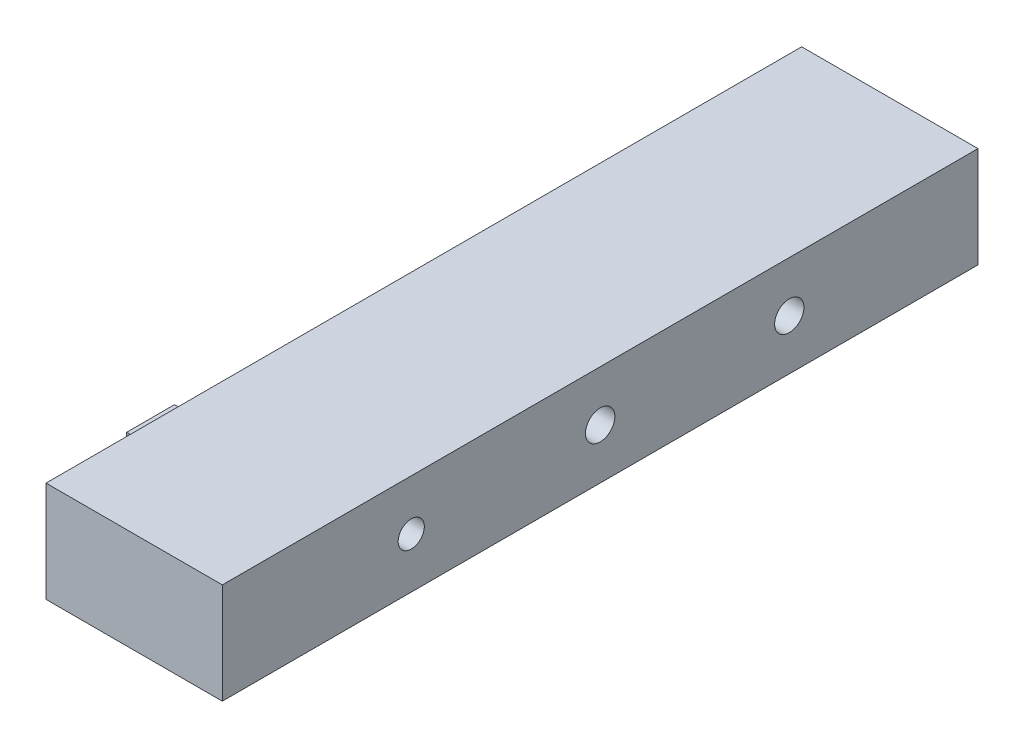
from build123d import *

# Parameters (mm, degrees)
SKETCH1_W                = 30
SKETCH1_H                = 4
BOSS_EXTRUDE1_DEPTH      = 7
SKETCH2_W                = 1.9
SKETCH2_H                = 1.9
BOSS_EXTRUDE2_DEPTH      = 1
SKETCH3_W                = 1.9
SKETCH3_H                = 1.769397694
BOSS_EXTRUDE3_DEPTH      = 1
BOSS_EXTRUDE3_DEPTH_BACK = 1
SKETCH4_R                = 0.519223145
SKETCH4_R_2              = 0.583770961
SKETCH4_R_3              = 0.581603631
CUT_EXTRUDE2_DEPTH       = 1
CUT_EXTRUDE2_DEPTH_BACK  = 3


with BuildPart() as part:
    # Sketch1 → Boss-Extrude1 (new body)
    with BuildSketch(Plane(origin=(0, 0, 0), x_dir=(0, 0, -1), z_dir=(1, 0, 0))):
        with Locations((15, 2)):
            Rectangle(SKETCH1_W, SKETCH1_H)
    extrude(amount=BOSS_EXTRUDE1_DEPTH)

    # Sketch2 → Boss-Extrude2 (add)
    with BuildSketch(Plane(origin=(0, 0, 0), x_dir=(0, 0, -1), z_dir=(1, 0, 0))):
        with Locations((5.150612861, 2.196174594)):
            Rectangle(SKETCH2_W, SKETCH2_H)
    extrude(amount=-BOSS_EXTRUDE2_DEPTH)

    # Sketch3 → Boss-Extrude3 (add, two sides)
    with BuildSketch(Plane(origin=(0, 0, 0), x_dir=(0, 0, -1), z_dir=(1, 0, 0))) as boss_extrude3_sk:
        with Locations((24.756915523, 2.019063583)):
            Rectangle(SKETCH3_W, SKETCH3_H)
    extrude(amount=BOSS_EXTRUDE3_DEPTH)
    extrude(boss_extrude3_sk.sketch, amount=-BOSS_EXTRUDE3_DEPTH_BACK)

    # Sketch4 → Cut-Extrude2 (cut, two sides)
    with BuildSketch(Plane(origin=(7, 0, 0), x_dir=(0, 0, -1), z_dir=(1, 0, 0))) as cut_extrude2_sk:
        with Locations((7.5, 2)):
            Circle(SKETCH4_R)
        with Locations((15, 2)):
            Circle(SKETCH4_R_2)
        with Locations((22.508486169, 2)):
            Circle(SKETCH4_R_3)
    extrude(amount=CUT_EXTRUDE2_DEPTH, mode=Mode.SUBTRACT)
    extrude(cut_extrude2_sk.sketch, amount=-CUT_EXTRUDE2_DEPTH_BACK, mode=Mode.SUBTRACT)


solid = part.part
